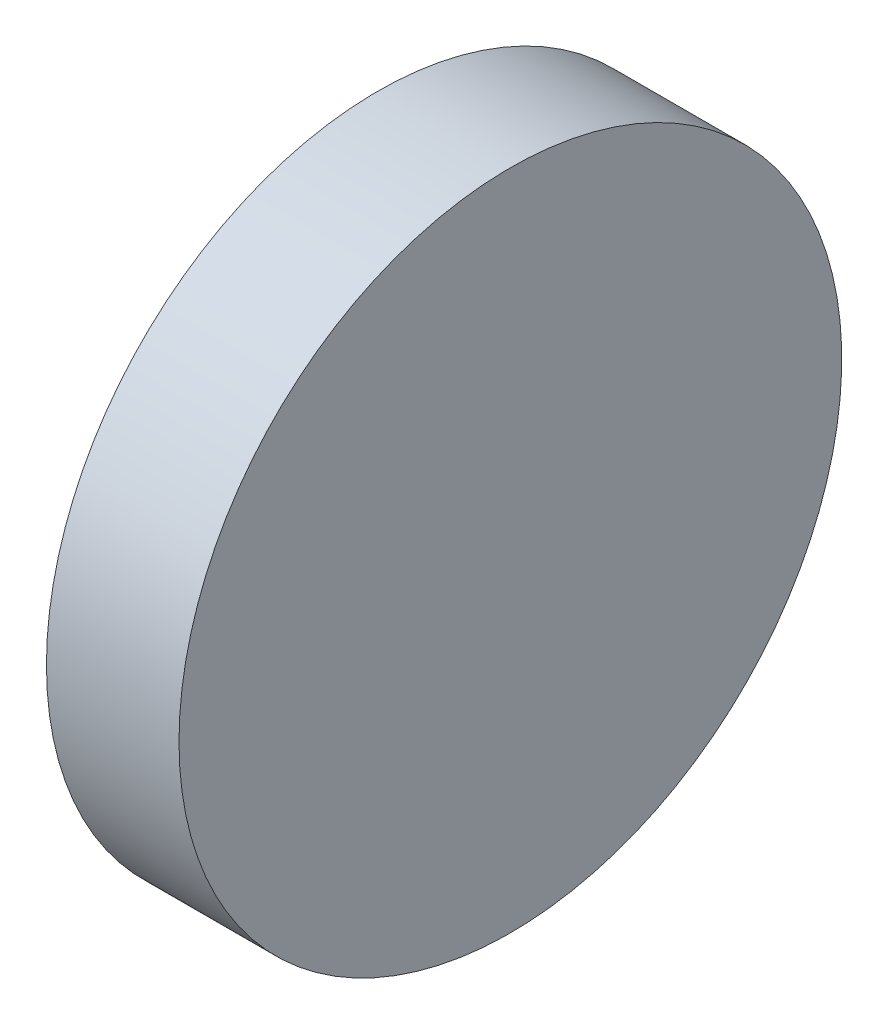
from build123d import *

# Parameters (mm, degrees)
SKETCH_1_W = 6
SKETCH_1_H = 12.7
SKETCH_4_W = 6
SKETCH_4_H = 2.3


with BuildPart() as part:
    # 草图1 → 旋转2 (revolve)
    with BuildSketch(Plane.XY, mode=Mode.PRIVATE) as revolve_2_sk:
        with Locations((0, 6.35)):
            Rectangle(SKETCH_1_W, SKETCH_1_H)
    revolve(revolve_2_sk.sketch.rotate(Axis((-3, 0, 0), (1, 0, 0)), 90), axis=Axis((-3, 0, 0), (1, 0, 0)))  # turned: the seam where the file's is

    # 草图4 → 旋转3 (revolve)
    with BuildSketch(Plane.XY, mode=Mode.PRIVATE) as revolve_3_sk:
        with Locations((0, 13.85)):
            Rectangle(SKETCH_4_W, SKETCH_4_H)
    revolve(revolve_3_sk.sketch.rotate(Axis((-1.614212419, 0, 0), (1, 0, 0)), 90), axis=Axis((-1.614212419, 0, 0), (1, 0, 0)))  # turned: the seam where the file's is


solid = part.part
